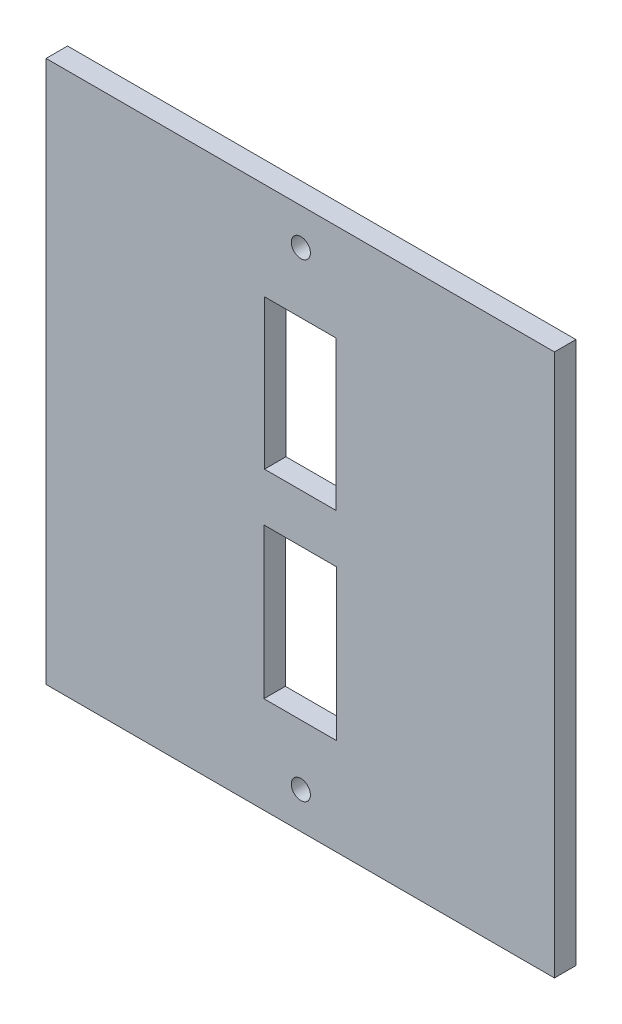
from build123d import *

# Parameters (mm, degrees)
SKETCH1_W           = 75.17
SKETCH1_H           = 80.17
SKETCH1_W_2         = 10.75
SKETCH1_H_2         = 22.25
SKETCH1_W_3         = 10.58
SKETCH1_H_3         = 22.08
BOSS_EXTRUDE1_DEPTH = 3.175
SKETCH2_R           = 1.415
CUT_EXTRUDE1_DEPTH  = 4.175


with BuildPart() as part:
    # Sketch1 → Boss-Extrude1 (new body)
    with BuildSketch(Plane.XY):
        Rectangle(SKETCH1_W, SKETCH1_H)
        with Locations((0, -14.675)):
            Rectangle(SKETCH1_W_2, SKETCH1_H_2, mode=Mode.SUBTRACT)
        with Locations((0, 14.675)):
            Rectangle(SKETCH1_W_3, SKETCH1_H_3, mode=Mode.SUBTRACT)
    extrude(amount=BOSS_EXTRUDE1_DEPTH)

    # Sketch2 → Cut-Extrude1 (cut, through all)
    with BuildSketch(Plane.XY.offset(3.175)):
        with Locations((0.085, 34.696699141)):
            Circle(SKETCH2_R)
        with Locations((0.085, -34.696699141)):
            Circle(SKETCH2_R)
    extrude(amount=-CUT_EXTRUDE1_DEPTH, mode=Mode.SUBTRACT)


solid = part.part
